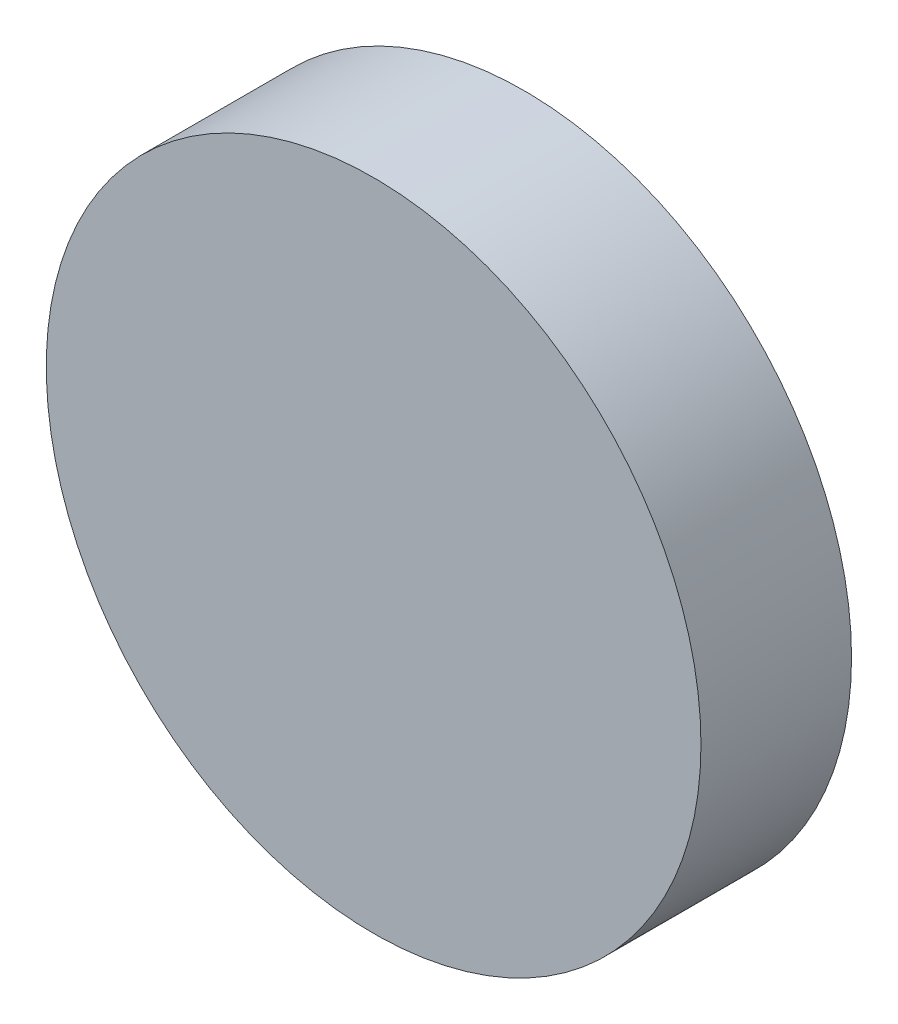
from build123d import *

# Parameters (mm, degrees)
SKETCH_1_R      = 5
EXTRUDE_1_DEPTH = 2.3


with BuildPart() as part:
    # 草图1 → 凸台-拉伸1 (new body)
    with BuildSketch(Plane.XY):
        with Locations((40.49917431, 24.625296734)):
            Circle(SKETCH_1_R)
    extrude(amount=EXTRUDE_1_DEPTH)


solid = part.part
